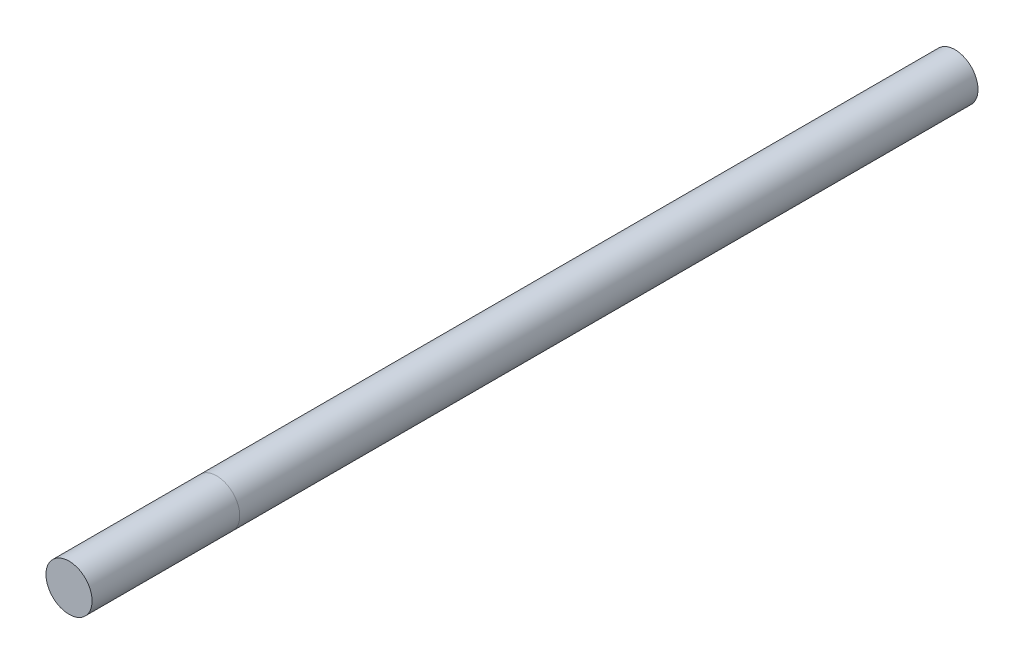
from build123d import *

# Parameters (mm, degrees)
SKETCH_1_R      = 2.5
EXTRUDE_1_DEPTH = 80
SKETCH_2_R      = 2.5
EXTRUDE_2_DEPTH = 16


with BuildPart() as part:
    # 草图1 → 凸台-拉伸1 (new body)
    with BuildSketch(Plane.XY):
        Circle(SKETCH_1_R)
    extrude(amount=EXTRUDE_1_DEPTH)


with BuildPart() as body_2:
    # 草图2 → 凸台-拉伸2 (new body)
    with BuildSketch(Plane.XY.offset(80)):
        Circle(SKETCH_2_R)
    extrude(amount=EXTRUDE_2_DEPTH)


solid = Compound([part.part, body_2.part])
